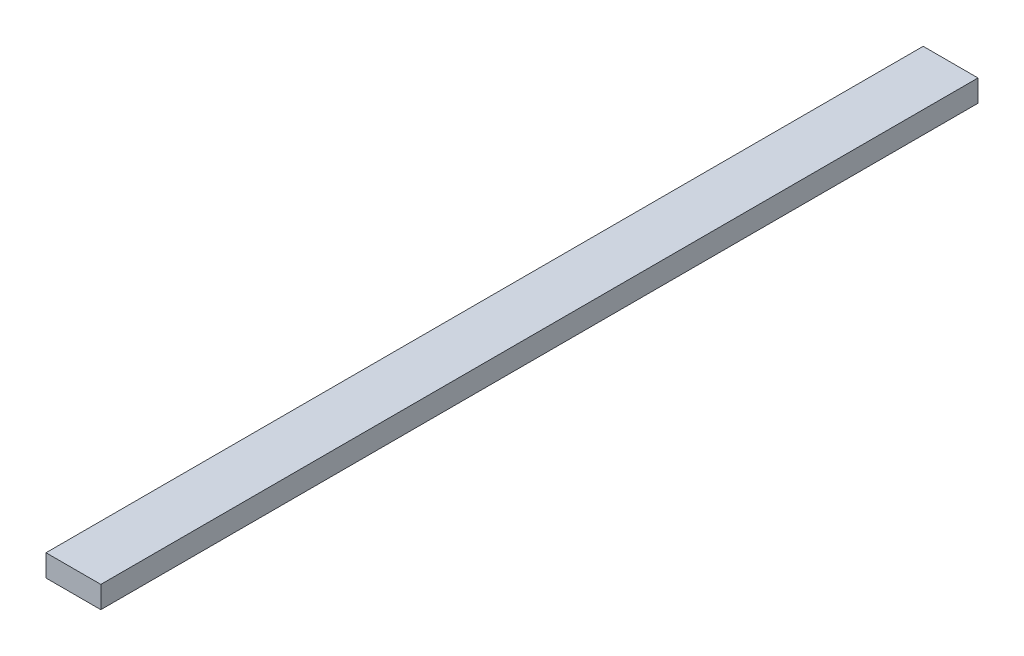
from build123d import *

# Parameters (mm, degrees)
SKETCH1_W           = 250
SKETCH1_H           = 4000
BOSS_EXTRUDE1_DEPTH = 100


with BuildPart() as part:
    # Sketch1 → Boss-Extrude1 (new body)
    with BuildSketch(Plane(origin=(0, 0, 0), x_dir=(1, 0, 0), z_dir=(0, 1, 0))):
        with Locations((125, 2000)):
            Rectangle(SKETCH1_W, SKETCH1_H)
    extrude(amount=BOSS_EXTRUDE1_DEPTH)


solid = part.part
